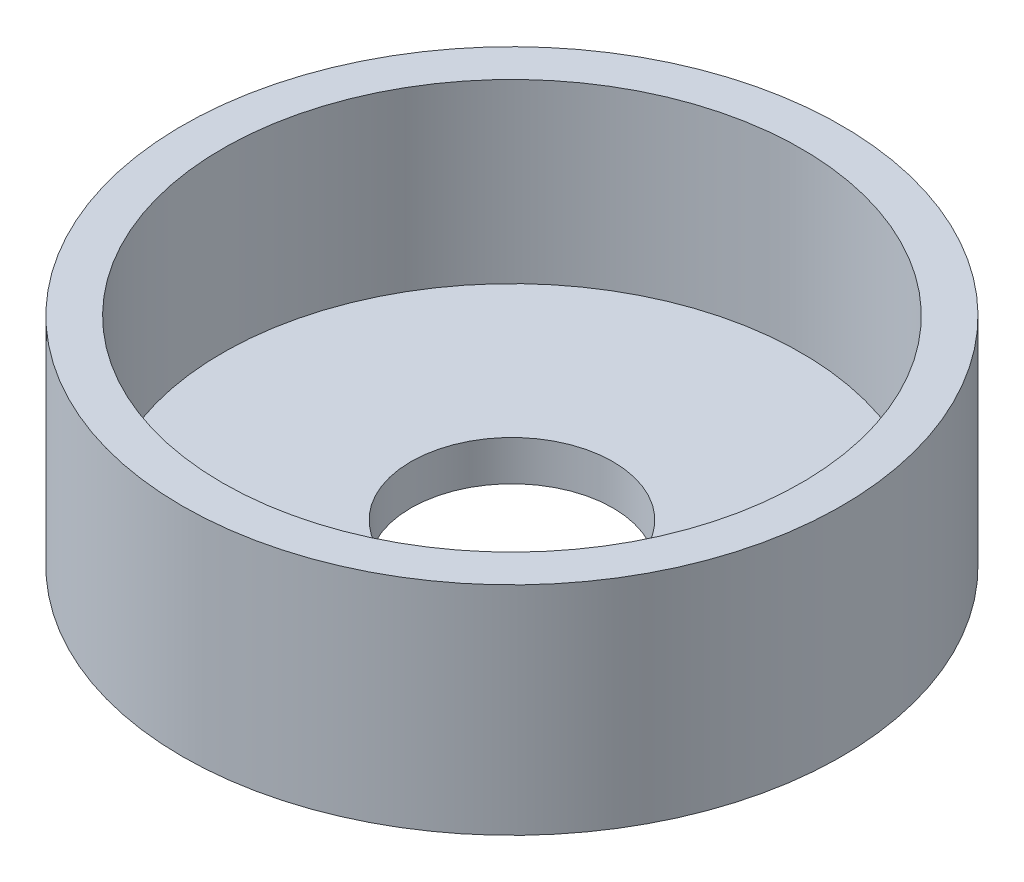
from build123d import *

# Parameters (mm, degrees)
SKETCH2_R           = 11.458333303
BOSS_EXTRUDE1_DEPTH = 1.5875
SKETCH5_R           = 13.045833303
BOSS_EXTRUDE4_DEPTH = 1.5875
BOSS_EXTRUDE5_START = 7
SKETCH5_4_R         = 13.045833303
SKETCH5_4_R_2       = 11.458333303
BOSS_EXTRUDE5_DEPTH = 7
SKETCH6_R           = 4.0005
CUT_EXTRUDE1_DEPTH  = 20.732904833


with BuildPart() as part:
    # Sketch2 → Boss-Extrude1 (new body)
    with BuildSketch(Plane(origin=(0, 0, 0), x_dir=(1, 0, 0), z_dir=(0, 1, 0))):
        Circle(SKETCH2_R)
    extrude(amount=BOSS_EXTRUDE1_DEPTH)

    # Sketch5 → Boss-Extrude4 (add)
    with BuildSketch(Plane(origin=(0, 1.5875, 0), x_dir=(1, 0, 0), z_dir=(0, 1, 0))):
        Circle(SKETCH5_R)
    extrude(amount=-BOSS_EXTRUDE4_DEPTH)

    # Sketch5_4 → Boss-Extrude5 (add)
    with BuildSketch(Plane(origin=(0, 1.5875, 0), x_dir=(1, 0, 0), z_dir=(0, 1, 0)).offset(BOSS_EXTRUDE5_START)):
        Circle(SKETCH5_4_R)
        Circle(SKETCH5_4_R_2, mode=Mode.SUBTRACT)
    extrude(amount=-BOSS_EXTRUDE5_DEPTH)

    # Sketch6 → Cut-Extrude1 (cut, through all)
    with BuildSketch(Plane(origin=(0, 1.5875, 0), x_dir=(1, 0, 0), z_dir=(0, 1, 0))):
        Circle(SKETCH6_R)
    extrude(amount=-CUT_EXTRUDE1_DEPTH, mode=Mode.SUBTRACT)


solid = part.part
